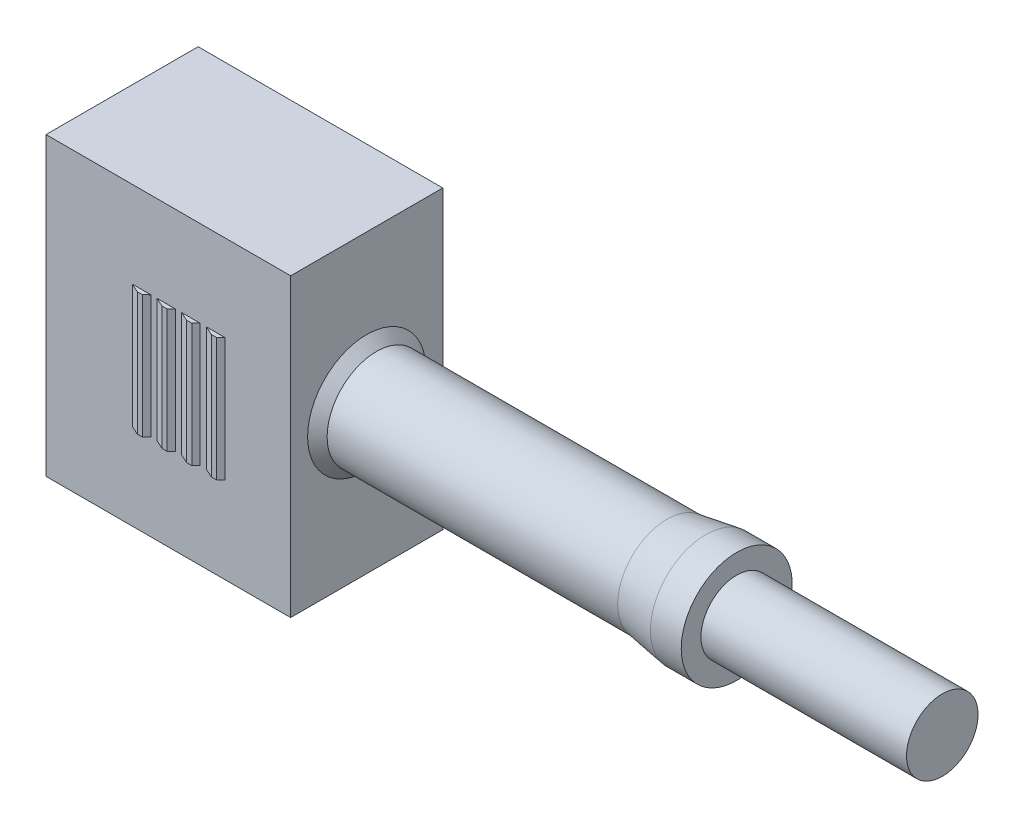
from build123d import *

# Parameters (mm, degrees)
SKETCH1_W      = 11.9
SKETCH1_H      = 14.4
EXTRUDE1_DEPTH = 3.7
EXTRUDE2_DEPTH = 3
SKETCH4_W      = 5.6
SKETCH4_H      = 12.8
EXTRUDE3_DEPTH = 4.5


with BuildPart() as part:
    # Sketch1 → Extrude1 (new body, symmetric)
    with BuildSketch(Plane.XY):
        Rectangle(SKETCH1_W, SKETCH1_H)
    extrude(amount=EXTRUDE1_DEPTH, both=True)

    # Sketch2 → Revolve1 (revolve)
    with BuildSketch(Plane.XY):
        Polygon((5.95, 0), (5.95, 2.875), (6.425, 2.4), (20.555874546, 2.4), (22.45, 2.7), (23.95, 2.7), (23.95, 1.74), (33.95, 1.74), (33.95, 0), align=None)
    revolve(axis=Axis((0, 0, 0), (1, 0, 0)))

    # Sketch3 → Extrude2 (add, symmetric)
    with BuildSketch(Plane(origin=(0, 0, 0), x_dir=(1, 0, 0), z_dir=(0, 1, 0))):
        Polygon((-1.75, -3.7), (-1.31, -3.9), (-1.06, -3.9), (-0.85, -3.7), align=None)
        Polygon((-0.55, -3.7), (0.35, -3.7), (0.14, -3.9), (-0.11, -3.9), align=None)
        Polygon((0.65, -3.7), (1.55, -3.7), (1.34, -3.9), (1.09, -3.9), align=None)
        Polygon((1.85, -3.7), (2.75, -3.7), (2.54, -3.9), (2.29, -3.9), align=None)
    extrude(amount=EXTRUDE2_DEPTH, both=True)

    # Sketch4 → Extrude3 (cut)
    with BuildSketch(Plane.ZY.offset(5.95)):
        Rectangle(SKETCH4_W, SKETCH4_H)
    extrude(amount=-EXTRUDE3_DEPTH, mode=Mode.SUBTRACT)


solid = part.part
